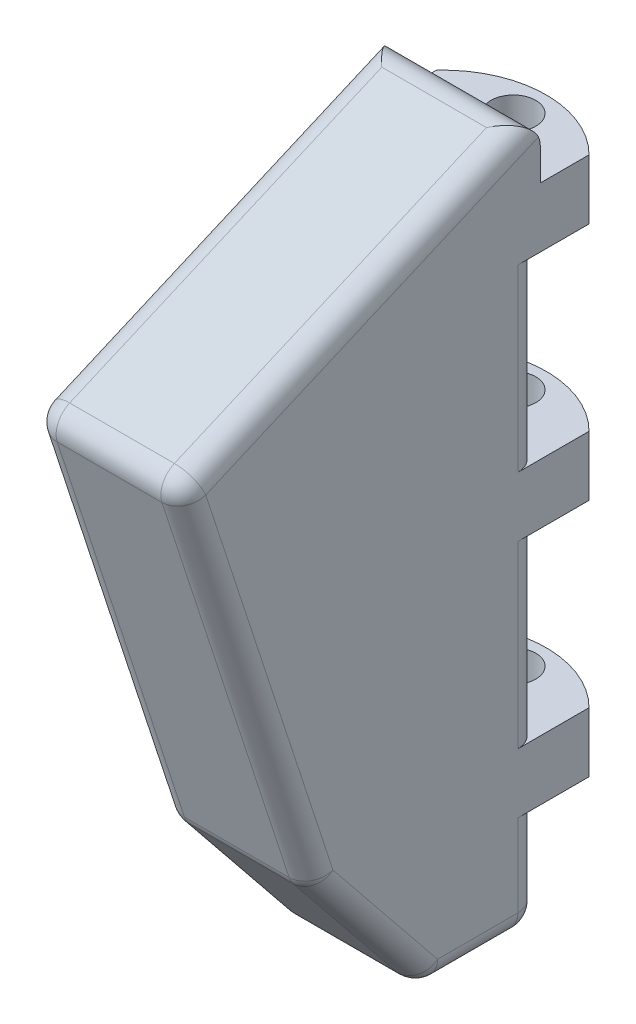
from build123d import *

# Parameters (mm, degrees)
SKETCH1_W           = 10
SKETCH1_H           = 50
BOSS_EXTRUDE1_DEPTH = 40
CUT_EXTRUDE1_DEPTH  = 40
CUT_EXTRUDE2_DEPTH  = 40
SKETCH4_W           = 10
SKETCH4_H           = 7
SKETCH4_H_2         = 12
CUT_EXTRUDE3_DEPTH  = 6
SKETCH5_R           = 1.5
CUT_EXTRUDE4_DEPTH  = 38
CUT_EXTRUDE5_DEPTH  = 38
FILLET1_R           = 1.5


with BuildPart() as part:
    # Sketch1 → Boss-Extrude1 (new body)
    with BuildSketch(Plane.XY):
        with Locations((5, -25)):
            Rectangle(SKETCH1_W, SKETCH1_H)
    extrude(amount=BOSS_EXTRUDE1_DEPTH)

    # Sketch2 → Cut-Extrude1 (cut)
    with BuildSketch(Plane(origin=(10, 0, 0), x_dir=(0, 0, -1), z_dir=(1, 0, 0))):
        Polygon((-27.429786362, -11.848127256), (0, 0), (-40, 0), (-40, -17.277753606), align=None)
        Polygon((-23.790339217, -37.357038236), (-40, -17.277753606), (-40, -50), (-13.583893856, -50), align=None)
    extrude(amount=-CUT_EXTRUDE1_DEPTH, mode=Mode.SUBTRACT)

    # Sketch3 → Cut-Extrude2 (cut)
    with BuildSketch(Plane(origin=(10, 0, 0), x_dir=(0, 0, -1), z_dir=(1, 0, 0))):
        Polygon((-30.211268677, -13.049571408), (-21.196168582, -40.570497868), (-40, -17.277753606), align=None)
    extrude(amount=-CUT_EXTRUDE2_DEPTH, mode=Mode.SUBTRACT)

    # Sketch4 → Cut-Extrude3 (cut)
    with BuildSketch(Plane(origin=(0, 0, 0), x_dir=(-1, 0, 0), z_dir=(0, 0, -1))):
        with Locations((-5, -3.5)):
            Rectangle(SKETCH4_W, SKETCH4_H)
        with Locations((-5, -17)):
            Rectangle(SKETCH4_W, SKETCH4_H_2)
        with Locations((-5, -33)):
            Rectangle(SKETCH4_W, SKETCH4_H_2)
        with Locations((-5, -46.5)):
            Rectangle(SKETCH4_W, SKETCH4_H)
    extrude(amount=-CUT_EXTRUDE3_DEPTH, mode=Mode.SUBTRACT)

    # Sketch5 → Cut-Extrude4 (cut)
    with BuildSketch(Plane.XZ.offset(43)):
        with Locations((5.065925619, 2.867770419)):
            Circle(SKETCH5_R)
    extrude(amount=-CUT_EXTRUDE4_DEPTH, mode=Mode.SUBTRACT)

    # Sketch6 → Cut-Extrude5 (cut)
    with BuildSketch(Plane.XZ.offset(43)):
        with BuildLine():
            ThreePointArc((10, 2.741877925), (4.957177855, 0.700758069), (0, 2.941876799))
            Line((0, 2.941876799), (0, 0))
            Line((0, 0), (10, 0))
            Line((10, 0), (10, 2.741877925))
        make_face()
    extrude(amount=-CUT_EXTRUDE5_DEPTH, mode=Mode.SUBTRACT)

    # Fillet1
    fillet1_edges = [part.edges().sort_by_distance(p)[0] for p in [
        (0, -7.820617225, 18.105634338),
        (5, -2.591663041, 6),
        (10, -7.820617225, 18.105634338),
        (0, -50, 9.791946928),
        (10, -50, 9.791946928),
        (5, -50, 6),
        (10, -45.285248934, 17.390031219),
        (5, -50, 13.583893856),
        (0, -45.285248934, 17.390031219),
        (0, -26.810034638, 25.703718629),
        (5, -13.049571408, 30.211268677),
        (10, -26.810034638, 25.703718629),
        (5, -40.570497868, 21.196168582),
        (0, -46.5, 6),
        (0, -33, 6),
        (0, -17, 6),
        (10, -46.5, 6),
        (10, -33, 6),
        (10, -17, 6),
    ]]
    fillet(fillet1_edges, radius=FILLET1_R)


solid = part.part
